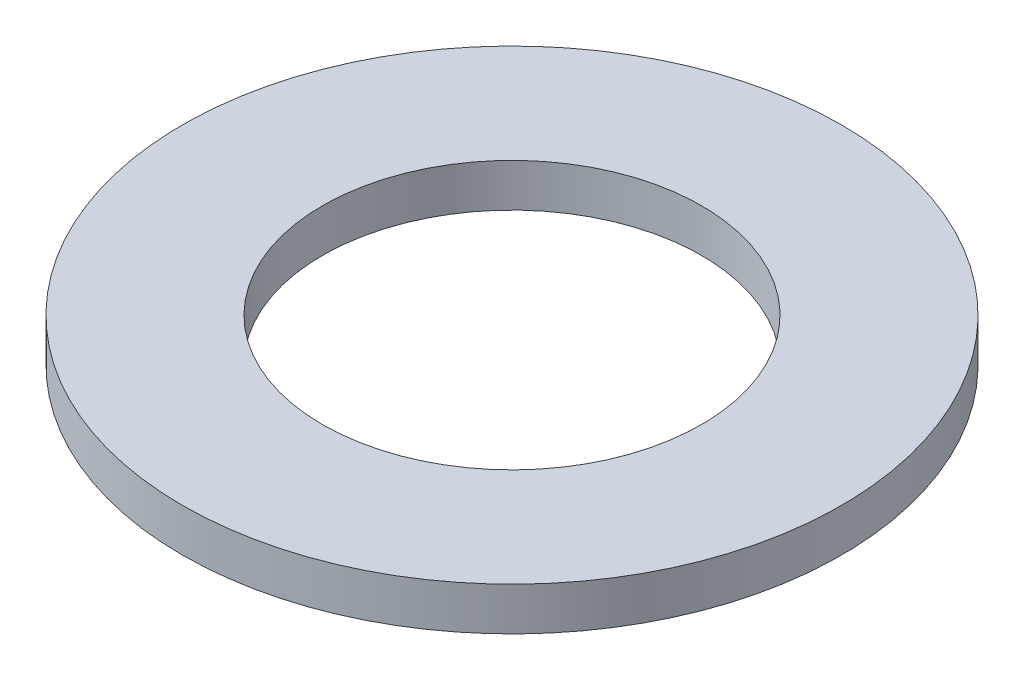
from build123d import *

# Parameters (mm, degrees)
SKETCH1_R           = 1.9431
BOSS_EXTRUDE1_DEPTH = 0.254
SKETCH5_R           = 1.1176
CUT_EXTRUDE1_DEPTH  = 1.254


with BuildPart() as part:
    # Sketch1 → Boss-Extrude1 (new body)
    with BuildSketch(Plane(origin=(0, 0, 0), x_dir=(1, 0, 0), z_dir=(0, 1, 0))):
        Circle(SKETCH1_R)
    extrude(amount=BOSS_EXTRUDE1_DEPTH)

    # Sketch5 → Cut-Extrude1 (cut, through all)
    with BuildSketch(Plane(origin=(0, 0.254, 0), x_dir=(-1, 0, 0), z_dir=(0, 1, 0))):
        Circle(SKETCH5_R)
    extrude(amount=-CUT_EXTRUDE1_DEPTH, mode=Mode.SUBTRACT)


solid = part.part
